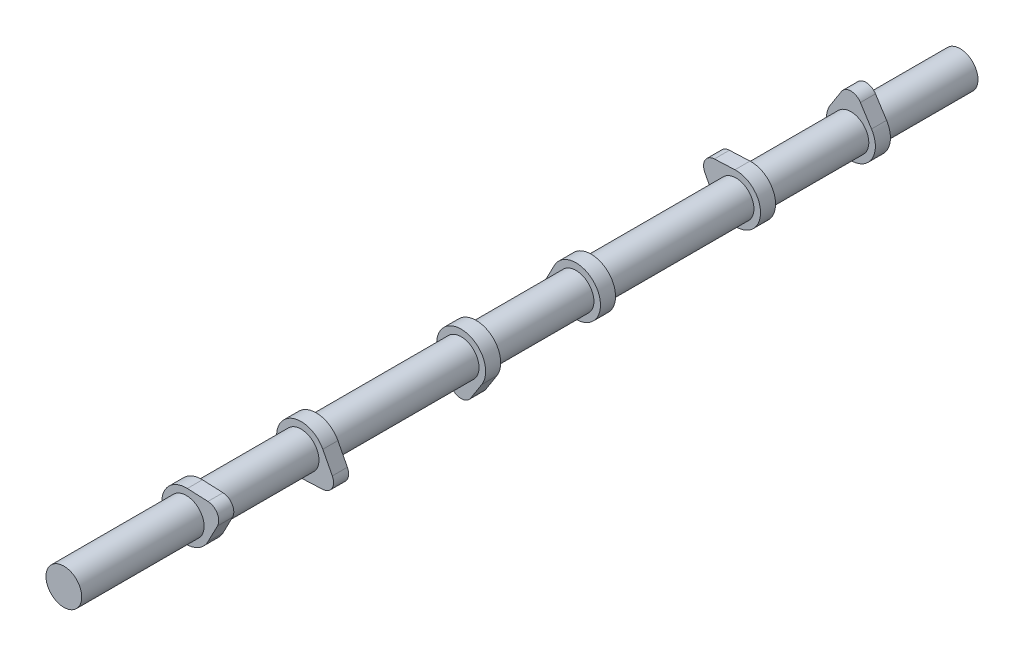
from build123d import *

# Parameters (mm, degrees)
SKETCH1_R           = 9.5
BOSS_EXTRUDE1_DEPTH = 476
BOSS_EXTRUDE2_DEPTH = 8
BOSS_EXTRUDE3_DEPTH = 8
BOSS_EXTRUDE4_DEPTH = 8
BOSS_EXTRUDE5_DEPTH = 8
BOSS_EXTRUDE6_DEPTH = 8
BOSS_EXTRUDE7_DEPTH = 8


with BuildPart() as part:
    # Sketch1 → Boss-Extrude1 (new body)
    with BuildSketch(Plane.XY):
        Circle(SKETCH1_R)
    extrude(amount=BOSS_EXTRUDE1_DEPTH)

    # Sketch2 → Boss-Extrude2 (add)
    with BuildSketch(Plane(origin=(0, 0, 50), x_dir=(-1, 0, 0), z_dir=(0, 0, -1))):
        with BuildLine():
            Line((-10.954451152, 6.999999997), (-5.055900535, 16.230769231))
            ThreePointArc((-5.055900535, 16.230769231), (-1e-09, 19.000000003), (5.055900534, 16.230769233))
            Line((5.055900534, 16.230769233), (10.954451152, 6.999999997))
            ThreePointArc((10.954451152, 6.999999997), (0, -13), (-10.954451152, 6.999999997))
        make_face()
    extrude(amount=-BOSS_EXTRUDE2_DEPTH)

    # Sketch3 → Boss-Extrude3 (add)
    with BuildSketch(Plane.XY.offset(111)):
        with BuildLine():
            Line((-0.584952247, 12.986832981), (-11.52830821, 12.493922918))
            ThreePointArc((-11.52830821, 12.493922918), (-16.454482674, 9.500000003), (-16.584208745, 3.736846315))
            Line((-16.584208745, 3.736846315), (-11.5394034, -5.986832984))
            ThreePointArc((-11.5394034, -5.986832984), (11.258330249, -6.5), (-0.584952247, 12.986832981))
        make_face()
    extrude(amount=BOSS_EXTRUDE3_DEPTH)

    # Sketch4 → Boss-Extrude4 (add)
    with BuildSketch(Plane.XY.offset(196)):
        with BuildLine():
            Line((-11.5394034, 5.986832984), (-16.584208744, -3.736846313))
            ThreePointArc((-16.584208744, -3.736846313), (-16.454482675, -9.500000001), (-11.528308212, -12.493922917))
            Line((-11.528308212, -12.493922917), (-0.584952247, -12.986832981))
            ThreePointArc((-0.584952247, -12.986832981), (11.258330249, 6.5), (-11.5394034, 5.986832984))
        make_face()
    extrude(amount=BOSS_EXTRUDE4_DEPTH)

    # Sketch5 → Boss-Extrude5 (add)
    with BuildSketch(Plane.XY.offset(257)):
        with BuildLine():
            Line((-10.954451152, -6.999999997), (-5.055900535, -16.230769231))
            ThreePointArc((-5.055900535, -16.230769231), (-1e-09, -19.000000003), (5.055900534, -16.230769233))
            Line((5.055900534, -16.230769233), (10.954451152, -6.999999997))
            ThreePointArc((10.954451152, -6.999999997), (0, 13), (-10.954451152, -6.999999997))
        make_face()
    extrude(amount=BOSS_EXTRUDE5_DEPTH)

    # Sketch6 → Boss-Extrude6 (add)
    with BuildSketch(Plane.XY.offset(342)):
        with BuildLine():
            Line((0.584952247, -12.986832981), (11.52830821, -12.493922918))
            ThreePointArc((11.52830821, -12.493922918), (16.454482674, -9.500000003), (16.584208745, -3.736846315))
            Line((16.584208745, -3.736846315), (11.5394034, 5.986832984))
            ThreePointArc((11.5394034, 5.986832984), (-11.258330249, 6.5), (0.584952247, -12.986832981))
        make_face()
    extrude(amount=BOSS_EXTRUDE6_DEPTH)

    # Sketch7 → Boss-Extrude7 (add)
    with BuildSketch(Plane.XY.offset(403)):
        with BuildLine():
            Line((11.5394034, -5.986832984), (16.584208744, 3.736846313))
            ThreePointArc((16.584208744, 3.736846313), (16.454482675, 9.500000001), (11.528308212, 12.493922917))
            Line((11.528308212, 12.493922917), (0.584952247, 12.986832981))
            ThreePointArc((0.584952247, 12.986832981), (-11.258330249, -6.5), (11.5394034, -5.986832984))
        make_face()
    extrude(amount=BOSS_EXTRUDE7_DEPTH)


solid = part.part
